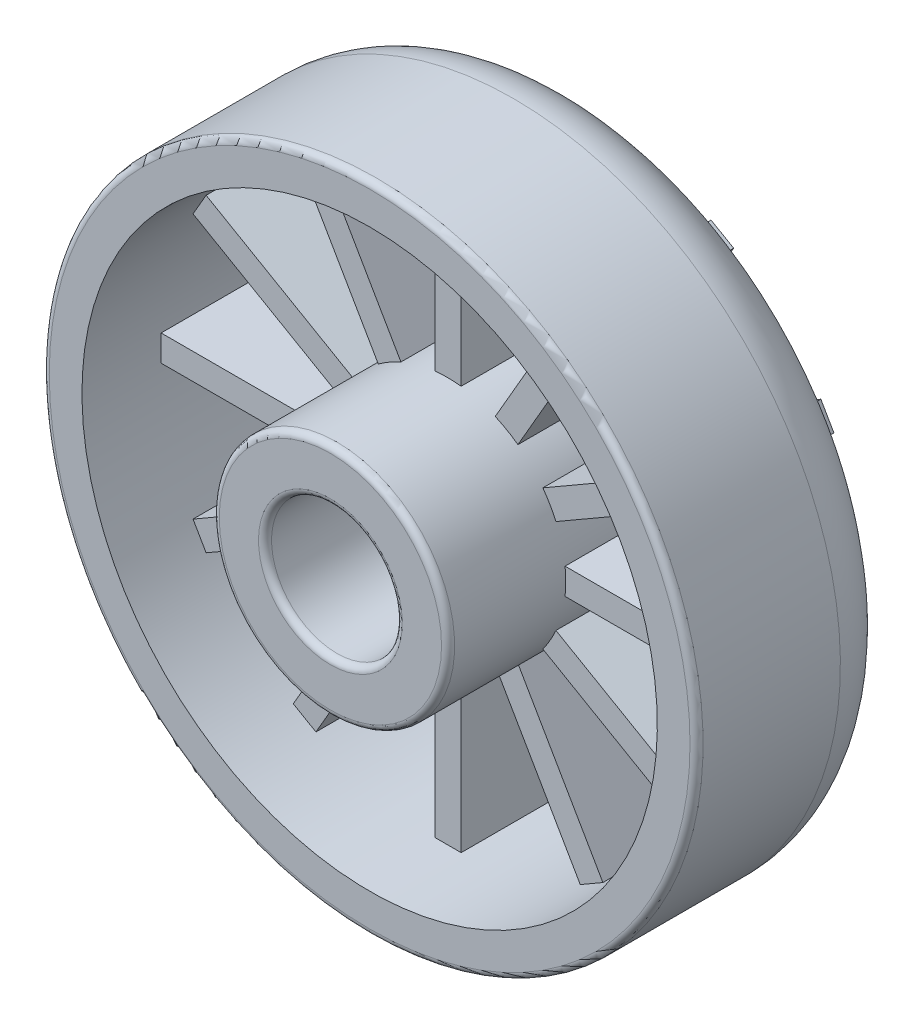
from build123d import *

# Parameters (mm, degrees)
FILLET1_R           = 5
BOSS_EXTRUDE1_DEPTH = 10
CIRPATTERN1_COUNT   = 12
SKETCH3_R           = 5
CUT_EXTRUDE1_DEPTH  = 14
FILLET2_R           = 0.5
FILLET3_R           = 0.5


with BuildPart() as part:
    # Sketch1 → Revolve1 (revolve)
    with BuildSketch(Plane(origin=(0, 0, 0), x_dir=(0, 0, -1), z_dir=(1, 0, 0))):
        Polygon((-8, 0), (8, 0), (8, -25), (-11, -25), (-11, -16), (5, -16), (5, -3), (-8, -3), align=None)
    revolve(axis=Axis((0, -25, -8), (0, 0, 1)))

    # Fillet1
    fillet1_edges = [part.edges().sort_by_distance(p)[0] for p in [
        (0, -50, -8),
    ]]
    fillet(fillet1_edges, radius=FILLET1_R)

    # Sketch2 → Boss-Extrude1 (add)
    with BuildSketch(Plane(origin=(0, 0, -8), x_dir=(-1, 0, 0), z_dir=(0, 0, -1))):
        with BuildLine():
            Line((-1, -3.05572809), (1, -3.05572809))
            Line((1, -3.05572809), (1, -16.05572809))
            ThreePointArc((1, -16.05572809), (0, -16), (-1, -16.05572809))
            Line((-1, -16.05572809), (-1, -3.05572809))
        make_face()
    boss_extrude1 = extrude(amount=-BOSS_EXTRUDE1_DEPTH)

    # CirPattern1: Boss-Extrude1 ×12 about axis
    cirpattern1_axis = Axis((0, -25, 0), (0, 0, 1))
    for i in range(1, CIRPATTERN1_COUNT):
        add(boss_extrude1.rotate(cirpattern1_axis, i * 360 / CIRPATTERN1_COUNT))

    # Sketch3 → Cut-Extrude1 (cut)
    with BuildSketch(Plane.XY.offset(11)):
        with Locations((0, -25)):
            Circle(SKETCH3_R)
    extrude(amount=-CUT_EXTRUDE1_DEPTH, mode=Mode.SUBTRACT)

    # Fillet2
    fillet2_edges = [part.edges().sort_by_distance(p)[0] for p in [
        (-5, -25, 11),
        (0, -34, 11),
    ]]
    fillet(fillet2_edges, radius=FILLET2_R)

    # Fillet3
    fillet3_edges = [part.edges().sort_by_distance(p)[0] for p in [
        (0, -50, 8),
    ]]
    fillet(fillet3_edges, radius=FILLET3_R)


solid = part.part
